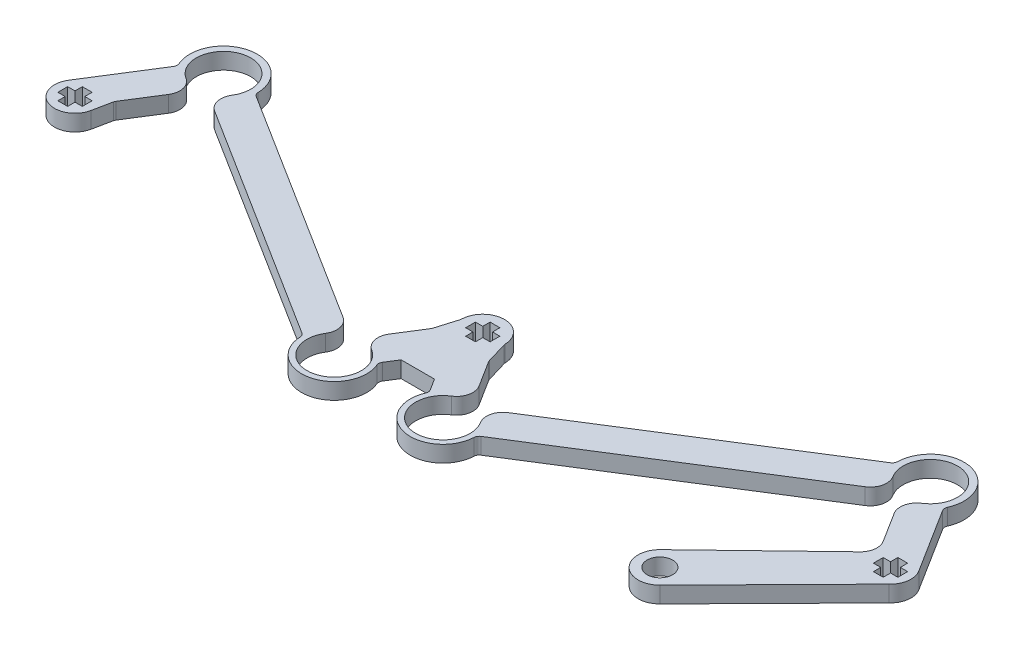
from build123d import *

# Parameters (mm, degrees)
SKETCH1_R           = 2.35
BOSS_EXTRUDE1_DEPTH = 3
FILLET1_R           = 3
FILLET2_R           = 1


with BuildPart() as part:
    # Sketch1 → Boss-Extrude1 (new body)
    with BuildSketch(Plane(origin=(0, 0, 0), x_dir=(1, 0, 0), z_dir=(0, 1, 0))):
        with BuildLine():
            Line((172.530209002, -85.760018057), (151.631467282, -106.990912204))
            ThreePointArc((151.631467282, -106.990912204), (145.936608589, -106.997416648), (146.006888843, -101.302987922))
            Line((146.006888843, -101.302987922), (166.487269252, -81.589717624))
            Line((166.487269252, -81.589717624), (159.587325171, -70.634585049))
            ThreePointArc((159.587325171, -70.634585049), (161.101414603, -60.775325043), (158.208232615, -70.321369913))
            Line((158.208232615, -70.321369913), (110.989592357, -100.061400455))
            ThreePointArc((110.989592357, -100.061400455), (103.665172589, -106.143163876), (99.686339562, -97.494241459))
            Line((99.686339562, -97.494241459), (98.064605927, -94.919393494))
            Line((98.064605927, -94.919393494), (91.923450353, -94.919393494))
            Line((91.923450353, -94.919393494), (90.301716718, -97.494241459))
            ThreePointArc((90.301716718, -97.494241459), (86.322883691, -106.143163876), (78.998463923, -100.061400455))
            Line((78.998463923, -100.061400455), (31.779823665, -70.321369913))
            ThreePointArc((31.779823665, -70.321369913), (28.886641677, -60.775325043), (30.400731109, -70.634585049))
            Line((30.400731109, -70.634585049), (24.422488643, -80.126319765))
            Line((24.422488643, -80.126319765), (23.686968876, -83.726197894))
            ThreePointArc((23.686968876, -83.726197894), (18.589619222, -86.469487176), (16.804675386, -80.962892486))
            Line((16.804675386, -80.962892486), (24.563909918, -68.643453086))
            ThreePointArc((24.563909918, -68.643453086), (28.620869821, -59.605126205), (36.183956221, -66.00434495))
            Line((36.183956221, -66.00434495), (83.208225156, -95.621953308))
            ThreePointArc((83.208225156, -95.621953308), (86.101407144, -105.167998178), (84.587317712, -95.308738171))
            Line((84.587317712, -95.308738171), (89.761234685, -87.094041689))
            Line((89.761234685, -87.094041689), (90.99402814, -82.971663764))
            ThreePointArc((90.99402814, -82.971663764), (94.99402814, -78.971663764), (98.99402814, -82.971663764))
            Line((98.99402814, -82.971663764), (100.212762732, -87.071720247))
            Line((100.212762732, -87.071720247), (105.400738568, -95.308738171))
            ThreePointArc((105.400738568, -95.308738171), (103.886649136, -105.167998178), (106.779831124, -95.621953308))
            Line((106.779831124, -95.621953308), (153.804100058, -66.00434495))
            ThreePointArc((153.804100058, -66.00434495), (161.367186459, -59.605126205), (165.424146361, -68.643453086))
            Line((165.424146361, -68.643453086), (173.183380893, -80.962892486))
            ThreePointArc((173.183380893, -80.962892486), (173.728802193, -83.480186919), (172.530209002, -85.760018057))
        make_face()
        with Locations((148.780829272, -104.184871767)):
            Circle(SKETCH1_R, mode=Mode.SUBTRACT)
        Polygon((167.74402814, -82.071663764), (167.74402814, -83.871663764), (169.09402814, -83.871663764), (169.09402814, -85.221663764), (170.89402814, -85.221663764), (170.89402814, -83.871663764), (172.24402814, -83.871663764), (172.24402814, -82.071663764), (170.89402814, -82.071663764), (170.89402814, -80.721663764), (169.09402814, -80.721663764), (169.09402814, -82.071663764), align=None, mode=Mode.SUBTRACT)
        Polygon((92.74402814, -82.071663764), (92.74402814, -83.871663764), (94.09402814, -83.871663764), (94.09402814, -85.221663764), (95.89402814, -85.221663764), (95.89402814, -83.871663764), (97.24402814, -83.871663764), (97.24402814, -82.071663764), (95.89402814, -82.071663764), (95.89402814, -80.721663764), (94.09402814, -80.721663764), (94.09402814, -82.071663764), align=None, mode=Mode.SUBTRACT)
        Polygon((17.74402814, -82.071663764), (17.74402814, -83.871663764), (19.09402814, -83.871663764), (19.09402814, -85.221663764), (20.89402814, -85.221663764), (20.89402814, -83.871663764), (22.24402814, -83.871663764), (22.24402814, -82.071663764), (20.89402814, -82.071663764), (20.89402814, -80.721663764), (19.09402814, -80.721663764), (19.09402814, -82.071663764), align=None, mode=Mode.SUBTRACT)
    extrude(amount=BOSS_EXTRUDE1_DEPTH)

    # Fillet1
    fillet1_edges = [part.edges().sort_by_distance(p)[0] for p in [
        (166.487269252, 1.5, 81.589717624),
        (159.587325171, 1.5, 70.634585049),
        (158.208232615, 1.5, 70.321369913),
        (31.779823665, 1.5, 70.321369913),
        (30.400731109, 1.5, 70.634585049),
        (83.208225156, 1.5, 95.621953308),
        (84.587317712, 1.5, 95.308738171),
        (105.400738568, 1.5, 95.308738171),
        (106.779831124, 1.5, 95.621953308),
    ]]
    fillet(fillet1_edges, radius=FILLET1_R)

    # Fillet2
    fillet2_edges = [part.edges().sort_by_distance(p)[0] for p in [
        (110.989592357, 1.5, 100.061400455),
        (99.686339562, 1.5, 97.494241459),
        (90.301716718, 1.5, 97.494241459),
        (78.998463923, 1.5, 100.061400455),
        (24.422488643, 1.5, 80.126319765),
        (24.563909918, 1.5, 68.643453086),
        (36.183956221, 1.5, 66.00434495),
        (89.761234685, 1.5, 87.094041689),
        (90.99402814, 1.5, 82.971663764),
        (98.99402814, 1.5, 82.971663764),
        (100.212762732, 1.5, 87.071720247),
        (153.804100058, 1.5, 66.00434495),
        (165.424146361, 1.5, 68.643453086),
    ]]
    fillet(fillet2_edges, radius=FILLET2_R)


solid = part.part
